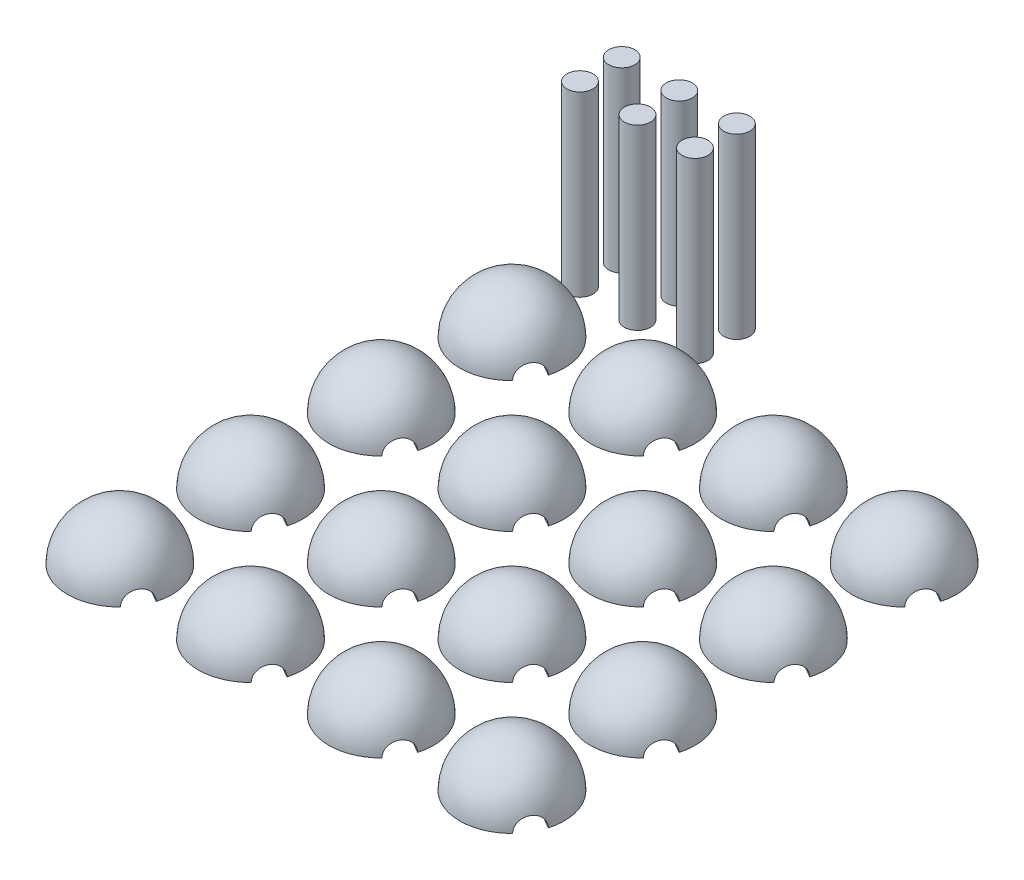
from build123d import *

# Parameters (mm, degrees)
REVOLVE1_ANGLE          = 180
SKETCH4_R               = 2.5
CUT_EXTRUDE2_DEPTH      = 11
SKETCH6_R               = 2.5
CUT_EXTRUDE3_DEPTH      = 11
BOSS_EXTRUDE3_DEPTH     = 3
BOSS_EXTRUDE4_DEPTH     = 3
SKETCH12_R              = 2.495
BOSS_EXTRUDE5_DEPTH     = 34
BOSS_EXTRUDE5_2_DEPTH   = 34
BOSS_EXTRUDE5_3_DEPTH   = 34
BOSS_EXTRUDE5_4_DEPTH   = 34
BOSS_EXTRUDE5_5_DEPTH   = 34
BOSS_EXTRUDE5_6_DEPTH   = 34
LPATTERN18_COUNT        = 4
LPATTERN18_PITCH        = 25
LPATTERN18_COUNT_DIR2   = 4
LPATTERN18_PITCH_DIR2   = 25
LPATTERN18_2_COUNT      = 4
LPATTERN18_2_PITCH      = 25
LPATTERN18_2_COUNT_DIR2 = 4
LPATTERN18_2_PITCH_DIR2 = 25
LPATTERN18_3_COUNT      = 4
LPATTERN18_3_PITCH      = 25
LPATTERN18_3_COUNT_DIR2 = 4
LPATTERN18_3_PITCH_DIR2 = 25


with BuildPart() as part:
    # Sketch1 → Revolve1 (revolve)
    with BuildSketch(Plane(origin=(0, 0, 0), x_dir=(1, 0, 0), z_dir=(0, 1, 0))):
        with BuildLine():
            Line((0, 10), (0, -10))
            ThreePointArc((0, -10), (-10, 0), (0, 10))
        make_face()
    revolve1 = revolve(axis=Axis((0, 0, -10), (0, 0, -1)), revolution_arc=REVOLVE1_ANGLE)

    # Sketch4 → Cut-Extrude2 (cut)
    with BuildSketch(Plane.XY):
        Circle(SKETCH4_R)
    cut_extrude2 = extrude(amount=-CUT_EXTRUDE2_DEPTH, mode=Mode.SUBTRACT)

    # Sketch6 → Cut-Extrude3 (cut)
    with BuildSketch(Plane(origin=(0, 0, 0), x_dir=(0.5, 0, -0.866025404), z_dir=(0.866025404, 0, 0.5))):
        Circle(SKETCH6_R)
    cut_extrude3 = extrude(amount=CUT_EXTRUDE3_DEPTH, mode=Mode.SUBTRACT)

    # Sketch10 → Boss-Extrude3 (add)
    with BuildSketch(Plane(origin=(0, 0, 0), x_dir=(0.5, 0, -0.866025404), z_dir=(0.866025404, 0, 0.5))):
        with BuildLine():
            Line((-2.5, 0), (2.5, 0))
            ThreePointArc((2.5, 0), (0, 2.5), (-2.5, 0))
        make_face()
    boss_extrude3 = extrude(amount=BOSS_EXTRUDE3_DEPTH)

    # Sketch11 → Boss-Extrude4 (add)
    with BuildSketch(Plane.XY):
        with BuildLine():
            Line((-2.5, 0), (2.5, 0))
            ThreePointArc((2.5, 0), (0, 2.5), (-2.5, 0))
        make_face()
    boss_extrude4 = extrude(amount=-BOSS_EXTRUDE4_DEPTH)


with BuildPart() as body_2:
    # Sketch12 → Boss-Extrude5 (new body)
    with BuildSketch(Plane(origin=(0, 0, 0), x_dir=(1, 0, 0), z_dir=(0, 1, 0))):
        with Locations((-2, 15)):
            Circle(SKETCH12_R)
    extrude(amount=BOSS_EXTRUDE5_DEPTH)


with BuildPart() as body_3:
    # Sketch12 → Boss-Extrude5 2 (new body)
    with BuildSketch(Plane(origin=(0, 0, 0), x_dir=(1, 0, 0), z_dir=(0, 1, 0))):
        with Locations((-2, 23)):
            Circle(SKETCH12_R)
    extrude(amount=BOSS_EXTRUDE5_2_DEPTH)


with BuildPart() as body_4:
    # Sketch12 → Boss-Extrude5 3 (new body)
    with BuildSketch(Plane(origin=(0, 0, 0), x_dir=(1, 0, 0), z_dir=(0, 1, 0))):
        with Locations((9, 23)):
            Circle(SKETCH12_R)
    extrude(amount=BOSS_EXTRUDE5_3_DEPTH)


with BuildPart() as body_5:
    # Sketch12 → Boss-Extrude5 4 (new body)
    with BuildSketch(Plane(origin=(0, 0, 0), x_dir=(1, 0, 0), z_dir=(0, 1, 0))):
        with Locations((9, 15)):
            Circle(SKETCH12_R)
    extrude(amount=BOSS_EXTRUDE5_4_DEPTH)


with BuildPart() as body_6:
    # Sketch12 → Boss-Extrude5 5 (new body)
    with BuildSketch(Plane(origin=(0, 0, 0), x_dir=(1, 0, 0), z_dir=(0, 1, 0))):
        with Locations((20, 23)):
            Circle(SKETCH12_R)
    extrude(amount=BOSS_EXTRUDE5_5_DEPTH)


with BuildPart() as body_7:
    # Sketch12 → Boss-Extrude5 6 (new body)
    with BuildSketch(Plane(origin=(0, 0, 0), x_dir=(1, 0, 0), z_dir=(0, 1, 0))):
        with Locations((20, 15)):
            Circle(SKETCH12_R)
    extrude(amount=BOSS_EXTRUDE5_6_DEPTH)


with BuildPart() as lpattern18_1:
    # LPattern18: pattern copy
    add(revolve1.moved(Location(Vector(1, 0, 0) * (0 * LPATTERN18_PITCH) + Vector(0, 0, 1) * (1 * LPATTERN18_PITCH_DIR2))))


with BuildPart() as lpattern18_2:
    # LPattern18: pattern copy
    add(revolve1.moved(Location(Vector(1, 0, 0) * (0 * LPATTERN18_PITCH) + Vector(0, 0, 1) * (2 * LPATTERN18_PITCH_DIR2))))


with BuildPart() as lpattern18_3:
    # LPattern18: pattern copy
    add(revolve1.moved(Location(Vector(1, 0, 0) * (0 * LPATTERN18_PITCH) + Vector(0, 0, 1) * (3 * LPATTERN18_PITCH_DIR2))))


with BuildPart() as lpattern18_4:
    # LPattern18: pattern copy
    add(revolve1.moved(Location(Vector(1, 0, 0) * (1 * LPATTERN18_PITCH) + Vector(0, 0, 1) * (0 * LPATTERN18_PITCH_DIR2))))


with BuildPart() as lpattern18_5:
    # LPattern18: pattern copy
    add(revolve1.moved(Location(Vector(1, 0, 0) * (1 * LPATTERN18_PITCH) + Vector(0, 0, 1) * (1 * LPATTERN18_PITCH_DIR2))))


with BuildPart() as lpattern18_6:
    # LPattern18: pattern copy
    add(revolve1.moved(Location(Vector(1, 0, 0) * (1 * LPATTERN18_PITCH) + Vector(0, 0, 1) * (2 * LPATTERN18_PITCH_DIR2))))


with BuildPart() as lpattern18_7:
    # LPattern18: pattern copy
    add(revolve1.moved(Location(Vector(1, 0, 0) * (1 * LPATTERN18_PITCH) + Vector(0, 0, 1) * (3 * LPATTERN18_PITCH_DIR2))))


with BuildPart() as lpattern18_8:
    # LPattern18: pattern copy
    add(revolve1.moved(Location(Vector(1, 0, 0) * (2 * LPATTERN18_PITCH) + Vector(0, 0, 1) * (0 * LPATTERN18_PITCH_DIR2))))


with BuildPart() as lpattern18_9:
    # LPattern18: pattern copy
    add(revolve1.moved(Location(Vector(1, 0, 0) * (2 * LPATTERN18_PITCH) + Vector(0, 0, 1) * (1 * LPATTERN18_PITCH_DIR2))))


with BuildPart() as lpattern18_10:
    # LPattern18: pattern copy
    add(revolve1.moved(Location(Vector(1, 0, 0) * (2 * LPATTERN18_PITCH) + Vector(0, 0, 1) * (2 * LPATTERN18_PITCH_DIR2))))


with BuildPart() as lpattern18_11:
    # LPattern18: pattern copy
    add(revolve1.moved(Location(Vector(1, 0, 0) * (2 * LPATTERN18_PITCH) + Vector(0, 0, 1) * (3 * LPATTERN18_PITCH_DIR2))))


with BuildPart() as lpattern18_12:
    # LPattern18: pattern copy
    add(revolve1.moved(Location(Vector(1, 0, 0) * (3 * LPATTERN18_PITCH) + Vector(0, 0, 1) * (0 * LPATTERN18_PITCH_DIR2))))


with BuildPart() as lpattern18_13:
    # LPattern18: pattern copy
    add(revolve1.moved(Location(Vector(1, 0, 0) * (3 * LPATTERN18_PITCH) + Vector(0, 0, 1) * (1 * LPATTERN18_PITCH_DIR2))))


with BuildPart() as lpattern18_14:
    # LPattern18: pattern copy
    add(revolve1.moved(Location(Vector(1, 0, 0) * (3 * LPATTERN18_PITCH) + Vector(0, 0, 1) * (2 * LPATTERN18_PITCH_DIR2))))


with BuildPart() as lpattern18_15:
    # LPattern18: pattern copy
    add(revolve1.moved(Location(Vector(1, 0, 0) * (3 * LPATTERN18_PITCH) + Vector(0, 0, 1) * (3 * LPATTERN18_PITCH_DIR2))))


with BuildPart() as lpattern18_2_tool:
    # LPattern18 2: Cut-Extrude2, Cut-Extrude3 4 × 4
    with Locations(*[(i * LPATTERN18_2_PITCH, 0, j * LPATTERN18_2_PITCH_DIR2) for i in range(LPATTERN18_2_COUNT) for j in range(LPATTERN18_2_COUNT_DIR2) if (i, j) != (0, 0)]):
        add(cut_extrude2)
        add(cut_extrude3)


with BuildPart() as lpattern18_1_1:
    add(lpattern18_1.part)

    # LPattern18 2: cut by lpattern18_2_tool
    add(lpattern18_2_tool.part, mode=Mode.SUBTRACT)



with BuildPart() as lpattern18_2_1:
    add(lpattern18_2.part)

    # LPattern18 2: cut by lpattern18_2_tool
    add(lpattern18_2_tool.part, mode=Mode.SUBTRACT)


with BuildPart() as lpattern18_3_1:
    add(lpattern18_3.part)

    # LPattern18 2: cut by lpattern18_2_tool
    add(lpattern18_2_tool.part, mode=Mode.SUBTRACT)


with BuildPart() as lpattern18_4_1:
    add(lpattern18_4.part)

    # LPattern18 2: cut by lpattern18_2_tool
    add(lpattern18_2_tool.part, mode=Mode.SUBTRACT)


with BuildPart() as lpattern18_5_1:
    add(lpattern18_5.part)

    # LPattern18 2: cut by lpattern18_2_tool
    add(lpattern18_2_tool.part, mode=Mode.SUBTRACT)


with BuildPart() as lpattern18_6_1:
    add(lpattern18_6.part)

    # LPattern18 2: cut by lpattern18_2_tool
    add(lpattern18_2_tool.part, mode=Mode.SUBTRACT)


with BuildPart() as lpattern18_7_1:
    add(lpattern18_7.part)

    # LPattern18 2: cut by lpattern18_2_tool
    add(lpattern18_2_tool.part, mode=Mode.SUBTRACT)


with BuildPart() as lpattern18_8_1:
    add(lpattern18_8.part)

    # LPattern18 2: cut by lpattern18_2_tool
    add(lpattern18_2_tool.part, mode=Mode.SUBTRACT)


with BuildPart() as lpattern18_9_1:
    add(lpattern18_9.part)

    # LPattern18 2: cut by lpattern18_2_tool
    add(lpattern18_2_tool.part, mode=Mode.SUBTRACT)


with BuildPart() as lpattern18_10_1:
    add(lpattern18_10.part)

    # LPattern18 2: cut by lpattern18_2_tool
    add(lpattern18_2_tool.part, mode=Mode.SUBTRACT)


with BuildPart() as lpattern18_11_1:
    add(lpattern18_11.part)

    # LPattern18 2: cut by lpattern18_2_tool
    add(lpattern18_2_tool.part, mode=Mode.SUBTRACT)


with BuildPart() as lpattern18_12_1:
    add(lpattern18_12.part)

    # LPattern18 2: cut by lpattern18_2_tool
    add(lpattern18_2_tool.part, mode=Mode.SUBTRACT)


with BuildPart() as lpattern18_13_1:
    add(lpattern18_13.part)

    # LPattern18 2: cut by lpattern18_2_tool
    add(lpattern18_2_tool.part, mode=Mode.SUBTRACT)


with BuildPart() as lpattern18_14_1:
    add(lpattern18_14.part)

    # LPattern18 2: cut by lpattern18_2_tool
    add(lpattern18_2_tool.part, mode=Mode.SUBTRACT)


with BuildPart() as lpattern18_15_1:
    add(lpattern18_15.part)

    # LPattern18 2: cut by lpattern18_2_tool
    add(lpattern18_2_tool.part, mode=Mode.SUBTRACT)


with BuildPart() as lpattern18_1_2:
    add(lpattern18_1_1.part)

    add(lpattern18_2_1.part)  # LPattern18 3 merges LPattern18_2

    add(lpattern18_3_1.part)  # LPattern18 3 merges LPattern18_3

    add(lpattern18_4_1.part)  # LPattern18 3 merges LPattern18_4

    add(lpattern18_5_1.part)  # LPattern18 3 merges LPattern18_5

    add(lpattern18_6_1.part)  # LPattern18 3 merges LPattern18_6

    add(lpattern18_7_1.part)  # LPattern18 3 merges LPattern18_7

    add(lpattern18_8_1.part)  # LPattern18 3 merges LPattern18_8

    add(lpattern18_9_1.part)  # LPattern18 3 merges LPattern18_9

    add(lpattern18_10_1.part)  # LPattern18 3 merges LPattern18_10

    add(lpattern18_11_1.part)  # LPattern18 3 merges LPattern18_11

    add(lpattern18_12_1.part)  # LPattern18 3 merges LPattern18_12

    add(lpattern18_13_1.part)  # LPattern18 3 merges LPattern18_13

    add(lpattern18_14_1.part)  # LPattern18 3 merges LPattern18_14

    add(lpattern18_15_1.part)  # LPattern18 3 merges LPattern18_15
    # LPattern18 3: Boss-Extrude3, Boss-Extrude4 4 × 4
    with Locations(*[(i * LPATTERN18_3_PITCH, 0, j * LPATTERN18_3_PITCH_DIR2) for i in range(LPATTERN18_3_COUNT) for j in range(LPATTERN18_3_COUNT_DIR2) if (i, j) != (0, 0)]):
        add(boss_extrude3)
        add(boss_extrude4)


solid = Compound([part.part, body_2.part, body_3.part, body_4.part, body_5.part, body_6.part, body_7.part, lpattern18_1_2.part])
